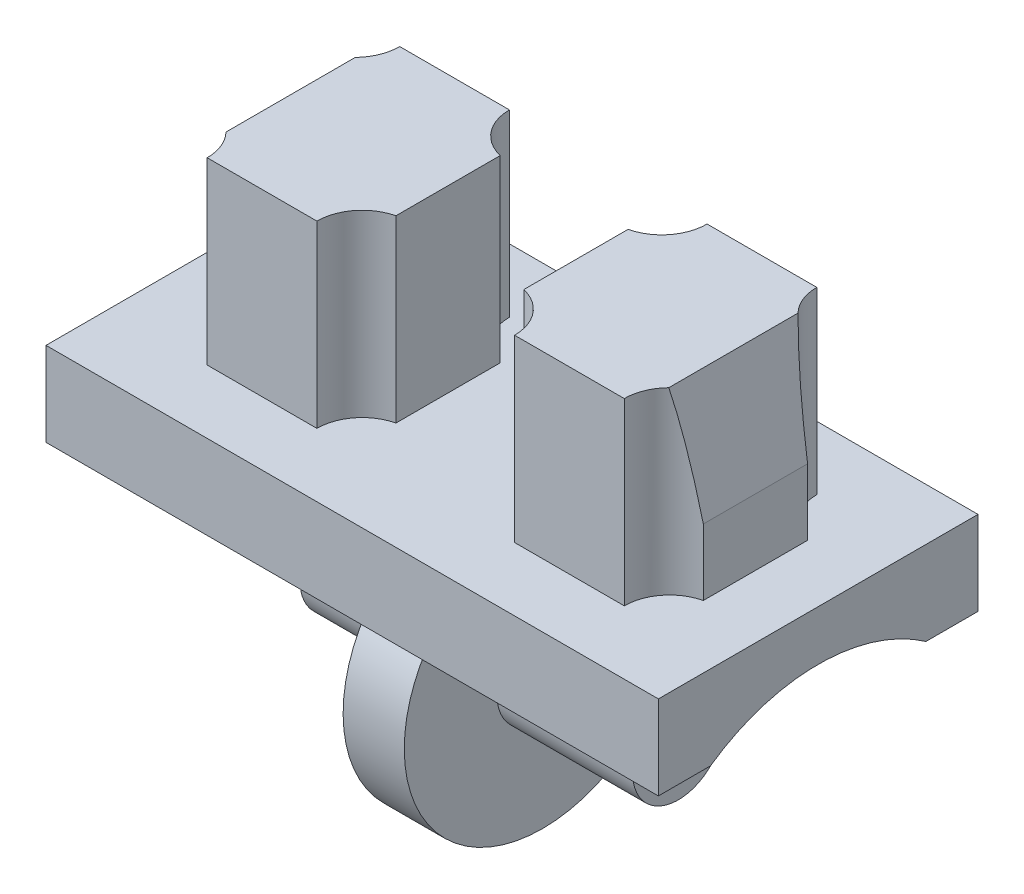
from build123d import *

# Parameters (mm, degrees)
IZIM3_W                     = 15.52
IZIM3_H                     = 8.1
Y_KSEKLIK_EKSTR_ZYON1_DEPTH = 2.13
Y_KSEKLIK_EKSTR_ZYON2_DEPTH = 4.55
KES_EKSTR_ZYON2_DEPTH       = 12.275
KES_EKSTR_ZYON3_DEPTH       = 12.275
KES_EKSTR_ZYON4_DEPTH       = 16.52
IZIM10_R                    = 3.505
IZIM10_R_2                  = 1.155
Y_KSEKLIK_EKSTR_ZYON4_DEPTH = 0.775
IZIM11_R                    = 1.155
Y_KSEKLIK_EKSTR_ZYON5_DEPTH = 4.215


with BuildPart() as part:
    # Çizim3 → Yükseklik-Ekstrüzyon1 (new body)
    with BuildSketch(Plane(origin=(0, 0, 0), x_dir=(1, 0, 0), z_dir=(0, 1, 0))):
        with Locations((-7.76, -4.05)):
            Rectangle(IZIM3_W, IZIM3_H)
    extrude(amount=-Y_KSEKLIK_EKSTR_ZYON1_DEPTH)

    # Çizim4 → Yükseklik-Ekstrüzyon2 (add)
    with BuildSketch(Plane(origin=(0, 0, 0), x_dir=(1, 0, 0), z_dir=(0, 1, 0))):
        with BuildLine():
            Line((-13.045, -1.61), (-10.265, -1.61))
            ThreePointArc((-10.265, -1.61), (-10.017011641, -2.32335475), (-9.38, -2.729050937))
            Line((-9.38, -2.729050937), (-9.38, -5.370949063))
            ThreePointArc((-9.38, -5.370949063), (-10.017011641, -5.77664525), (-10.265, -6.49))
            Line((-10.265, -6.49), (-13.045, -6.49))
            ThreePointArc((-13.045, -6.49), (-13.292988359, -5.77664525), (-13.93, -5.370949063))
            Line((-13.93, -5.370949063), (-13.93, -2.729050937))
            ThreePointArc((-13.93, -2.729050937), (-13.292988359, -2.32335475), (-13.045, -1.61))
        make_face()
        with BuildLine():
            Line((-6.14, -2.729050937), (-6.14, -5.370949063))
            ThreePointArc((-6.14, -5.370949063), (-5.502988359, -5.77664525), (-5.255, -6.49))
            Line((-5.255, -6.49), (-2.475, -6.49))
            ThreePointArc((-2.475, -6.49), (-2.227011641, -5.77664525), (-1.59, -5.370949063))
            Line((-1.59, -5.370949063), (-1.59, -2.729050937))
            ThreePointArc((-1.59, -2.729050937), (-2.227011641, -2.32335475), (-2.475, -1.61))
            Line((-2.475, -1.61), (-5.255, -1.61))
            ThreePointArc((-5.255, -1.61), (-5.502988359, -2.32335475), (-6.14, -2.729050937))
        make_face()
    extrude(amount=Y_KSEKLIK_EKSTR_ZYON2_DEPTH)

    # Çizim6 → Kes-Ekstrüzyon2 (cut, symmetric)
    with BuildSketch(Plane.XY.offset(5.370949063)):
        Polygon((-1.59, 1.68), (-1.59, 4.55), (-2.148911229, 4.55), align=None)
    extrude(amount=KES_EKSTR_ZYON2_DEPTH, both=True, mode=Mode.SUBTRACT)

    # Çizim7 → Kes-Ekstrüzyon3 (cut, symmetric)
    with BuildSketch(Plane.XY.offset(5.370949063)):
        Polygon((-13.93, 4.55), (-13.371088771, 4.55), (-13.93, 1.68), align=None)
    extrude(amount=KES_EKSTR_ZYON3_DEPTH, both=True, mode=Mode.SUBTRACT)

    # Çizim8 → Kes-Ekstrüzyon4 (cut, through all)
    with BuildSketch(Plane(origin=(0, 0, 0), x_dir=(0, 0, -1), z_dir=(1, 0, 0))):
        with BuildLine():
            ThreePointArc((-6.78, -2.13), (-4.05, -1.267106893), (-1.32, -2.13))
            Line((-1.32, -2.13), (-6.78, -2.13))
        make_face()
    extrude(amount=-KES_EKSTR_ZYON4_DEPTH, mode=Mode.SUBTRACT)

    # Çizim10 → Yükseklik-Ekstrüzyon4 (add, symmetric)
    with BuildSketch(Plane(origin=(-7.76, 0, 0), x_dir=(0, 0, -1), z_dir=(1, 0, 0))):
        with BuildLine():
            Line((-6.78, -2.13), (-6.78, -2.661790501))
            ThreePointArc((-6.78, -2.661790501), (-4.05, -1.355), (-1.32, -2.661790501))
            Line((-1.32, -2.661790501), (-1.32, -2.13))
            ThreePointArc((-1.32, -2.13), (-4.05, -1.267106893), (-6.78, -2.13))
        make_face()
        with Locations((-4.05, -4.86)):
            Circle(IZIM10_R)
        with Locations((-4.05, -4.86)):
            Circle(IZIM10_R_2, mode=Mode.SUBTRACT)
    extrude(amount=Y_KSEKLIK_EKSTR_ZYON4_DEPTH, both=True)

    # Çizim11 → Yükseklik-Ekstrüzyon5 (add, symmetric)
    with BuildSketch(Plane(origin=(-7.76, 0, 0), x_dir=(0, 0, -1), z_dir=(1, 0, 0))):
        with Locations((-4.05, -4.86)):
            Circle(IZIM11_R)
    extrude(amount=Y_KSEKLIK_EKSTR_ZYON5_DEPTH, both=True)


solid = part.part
